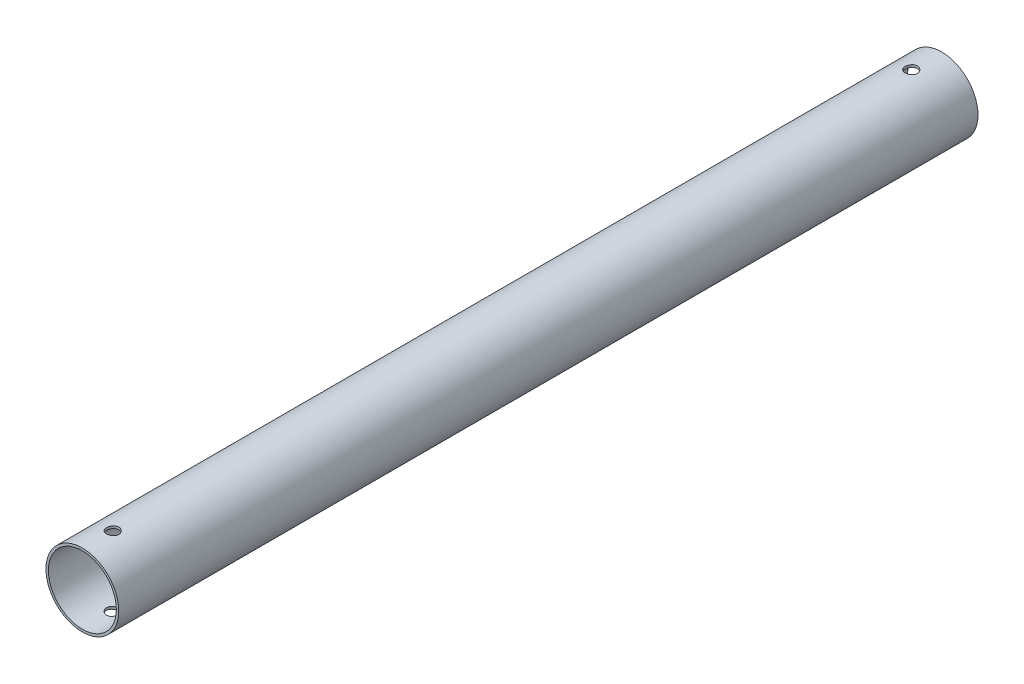
from build123d import *

# Parameters (mm, degrees)
SKETCH1_R               = 30
SKETCH1_R_2             = 28
BOSS_EXTRUDE1_DEPTH     = 708
SKETCH2_R               = 5
CUT_EXTRUDE1_DEPTH      = 31
CUT_EXTRUDE1_DEPTH_BACK = 31


with BuildPart() as part:
    # Sketch1 → Boss-Extrude1 (new body)
    with BuildSketch(Plane.XY):
        Circle(SKETCH1_R)
        Circle(SKETCH1_R_2, mode=Mode.SUBTRACT)
    extrude(amount=BOSS_EXTRUDE1_DEPTH)

    # Sketch2 → Cut-Extrude1 (cut, two sides)
    with BuildSketch(Plane(origin=(0, 0, 0), x_dir=(1, 0, 0), z_dir=(0, 1, 0))) as cut_extrude1_sk:
        with Locations((0, -683)):
            Circle(SKETCH2_R)
        with Locations((0, -25)):
            Circle(SKETCH2_R)
    extrude(amount=CUT_EXTRUDE1_DEPTH, mode=Mode.SUBTRACT)
    extrude(cut_extrude1_sk.sketch, amount=-CUT_EXTRUDE1_DEPTH_BACK, mode=Mode.SUBTRACT)


solid = part.part
